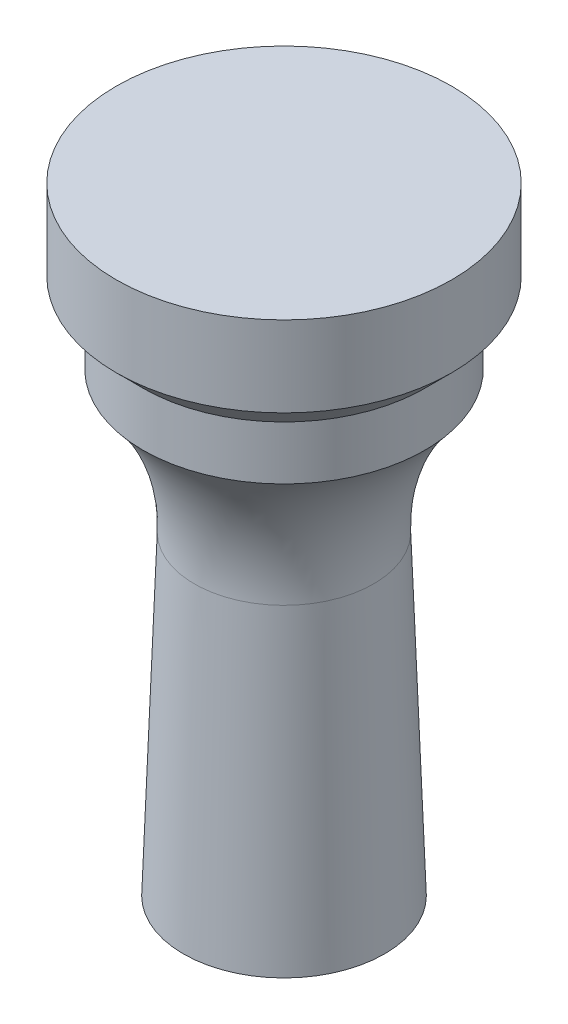
from build123d import *


with BuildPart() as part:
    # Sketch1 → Revolve1 (revolve)
    with BuildSketch(Plane.XY, mode=Mode.PRIVATE) as revolve1_sk:
        with BuildLine():
            Line((0, 48), (12.5, 48))
            Line((12.5, 48), (12.5, 42))
            Line((12.5, 42), (10.5, 40))
            Line((10.5, 40), (10.5, 36))
            ThreePointArc((10.5, 36), (7.569816074, 31.103274793), (6.680531261, 25.466514365))
            Line((6.680531261, 25.466514365), (7.5, 2))
            Line((7.5, 2), (2, 2))
            Line((2, 2), (0, 0))
            Line((0, 0), (0, 48))
        make_face()
    revolve(revolve1_sk.sketch.rotate(Axis((0, 0, 0), (0, 1, 0)), 90), axis=Axis((0, 0, 0), (0, 1, 0)))  # turned: the seam where the file's is


solid = part.part
